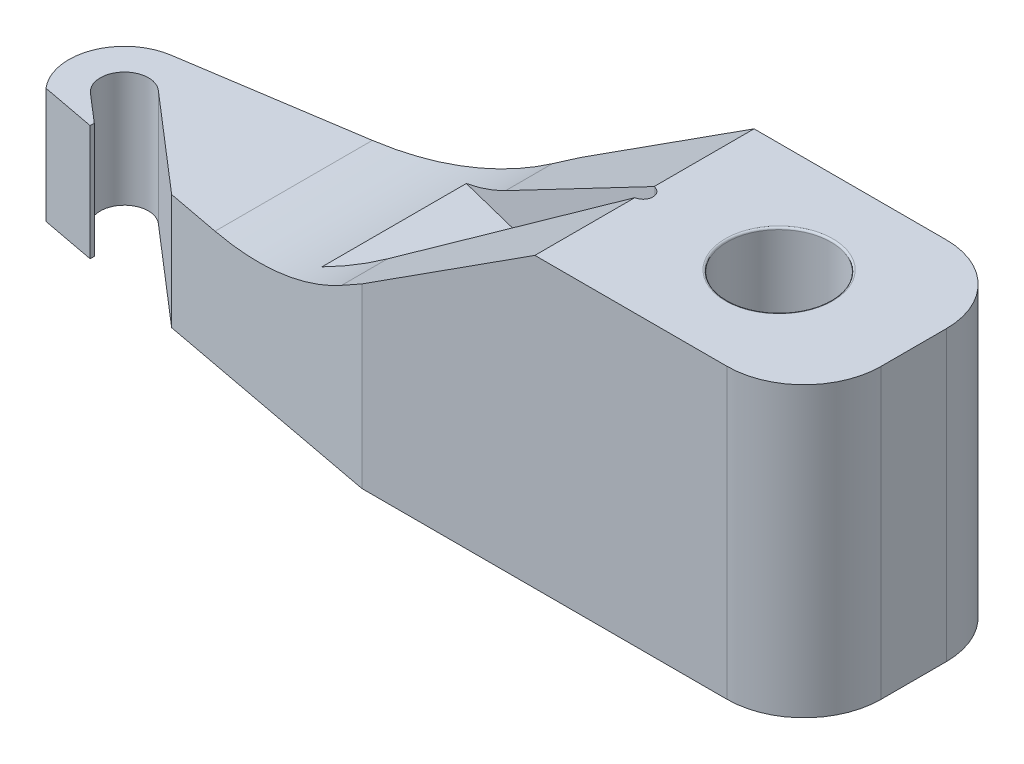
from build123d import *

# Parameters (mm, degrees)
SKETCH1_R               = 0.27
BOSS_EXTRUDE1_DEPTH     = 1.5
CUT_EXTRUDE1_DEPTH      = 1.57
CUT_EXTRUDE1_DEPTH_BACK = 1.57
FILLET1_R               = 0.01
FILLET2_R               = 1.5
FILLET3_R               = 0.4
CUT_EXTRUDE2_DEPTH      = 0.8
FILLET4_R               = 0.05


with BuildPart() as part:
    # Sketch1 → Boss-Extrude1 (new body)
    with BuildSketch(Plane(origin=(0, 0, 0), x_dir=(1, 0, 0), z_dir=(0, 1, 0))):
        with BuildLine():
            Line((0.7, -0.57), (0.7, 0.57))
            Line((0.7, 0.57), (-1.6, 0.57))
            Line((-1.6, 0.57), (-3.448849779, 0.285704322))
            ThreePointArc((-3.448849779, 0.285704322), (-3.676095639, 0.10009665), (-3.623939692, -0.188643104))
            Line((-3.623939692, -0.188643104), (-3.34104042, -0.241947849))
            Line((-3.34104042, -0.241947849), (-3.34104042, -0.220416717))
            Line((-3.34104042, -0.220416717), (-3.486679159, -0.094774919))
            ThreePointArc((-3.486679159, -0.094774919), (-3.499692238, 0.08176184), (-3.323155479, 0.094774919))
            Line((-3.323155479, 0.094774919), (-2.818770339, -0.340355572))
            Line((-2.818770339, -0.340355572), (-1.6, -0.57))
            Line((-1.6, -0.57), (0.7, -0.57))
        make_face()
        Circle(SKETCH1_R, mode=Mode.SUBTRACT)
    extrude(amount=BOSS_EXTRUDE1_DEPTH)

    # Sketch2 → Cut-Extrude1 (cut, two sides)
    with BuildSketch(Plane.XY) as cut_extrude1_sk:
        Polygon((-4.254461252, 0.6), (-2.1, 0.6), (-0.7, 1.5), (-4.254461252, 1.5), align=None)
    extrude(amount=CUT_EXTRUDE1_DEPTH, mode=Mode.SUBTRACT)
    extrude(cut_extrude1_sk.sketch, amount=-CUT_EXTRUDE1_DEPTH_BACK, mode=Mode.SUBTRACT)

    # Fillet1
    fillet1_edges = [part.edges().sort_by_distance(p)[0] for p in [
        (-0.27, 0, 0),
        (-0.27, 1.5, 0),
    ]]
    fillet(fillet1_edges, radius=FILLET1_R)

    # Fillet2
    fillet2_edges = [part.edges().sort_by_distance(p)[0] for p in [
        (-2.1, 0.6, -0.008663527),
    ]]
    fillet(fillet2_edges, radius=FILLET2_R)

    # Fillet3
    fillet3_edges = [part.edges().sort_by_distance(p)[0] for p in [
        (0.7, 0.75, -0.57),
        (0.7, 0.75, 0.57),
    ]]
    fillet(fillet3_edges, radius=FILLET3_R)

    # Sketch4 → Cut-Extrude2 (cut)
    with BuildSketch(Plane(origin=(0, 1.5, 0), x_dir=(1, 0, 0), z_dir=(0, 1, 0))):
        Polygon((-0.5, 0), (-2.5, 0.5), (-2.5, -0.5), align=None)
    extrude(amount=-CUT_EXTRUDE2_DEPTH, mode=Mode.SUBTRACT)

    # Fillet4
    fillet4_edges = [part.edges().sort_by_distance(p)[0] for p in [
        (-0.5, 1.1, 0),
    ]]
    fillet(fillet4_edges, radius=FILLET4_R)


solid = part.part
